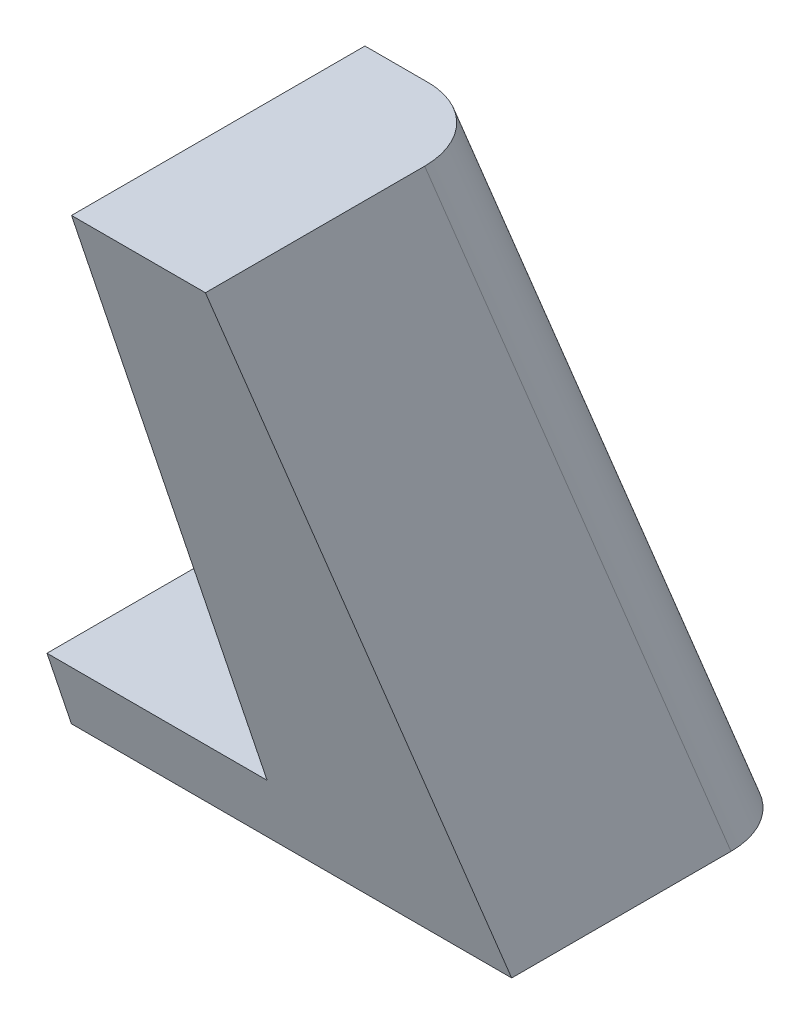
from build123d import *

# Parameters (mm, degrees)
EXTRUDE_6_DEPTH     = 50
CUT_EXTRUDE_5_DEPTH = 63
EXTRUDE_7_DEPTH     = 15
FILLET_2_R          = 5
SKETCH_8_R          = 2.5
CUT_EXTRUDE_6_DEPTH = 10


with BuildPart() as part:
    # Эскиз2 → Бобышка-Вытянуть6 (new body)
    with BuildSketch(Plane.XY):
        Polygon((39.125, 45), (30, 45), (30, 0), (45, 0), align=None)
    extrude(amount=-EXTRUDE_6_DEPTH)

    # Эскиз4 → Вырез-Вытянуть5 (cut)
    with BuildSketch(Plane(origin=(0, 0, 0), x_dir=(0, 0, -1), z_dir=(1, 0, 0))):
        Polygon((50.288969981, 0), (35.288969981, 45), (50, 45), align=None)
        Polygon((0, 45), (0, 0), (30.288969981, 0), (15.293288519, 45), align=None)
    extrude(amount=CUT_EXTRUDE_5_DEPTH, mode=Mode.SUBTRACT)

    # Эскиз7 → Бобышка-Вытянуть7 (add)
    with BuildSketch(Plane.ZY.offset(-30)):
        Polygon((-50, 0), (-50, 0.866909943), (-48.622303314, 5), (-28.622783152, 5), (-30.288969981, 0), align=None)
    extrude(amount=EXTRUDE_7_DEPTH)

    # Скругление2
    fillet_2_edges = [part.edges().sort_by_distance(p)[0] for p in [
        (42.005910045, 22.933454971, -42.64448499),
    ]]
    fillet(fillet_2_edges, radius=FILLET_2_R)

    # Эскиз8 → Вырез-Вытянуть6 (cut)
    with BuildSketch(Plane(origin=(0, 5, 0), x_dir=(1, 0, 0), z_dir=(0, 1, 0))):
        with Locations((22.5, 38.622543233)):
            Circle(SKETCH_8_R)
    extrude(amount=-CUT_EXTRUDE_6_DEPTH, mode=Mode.SUBTRACT)


solid = part.part
